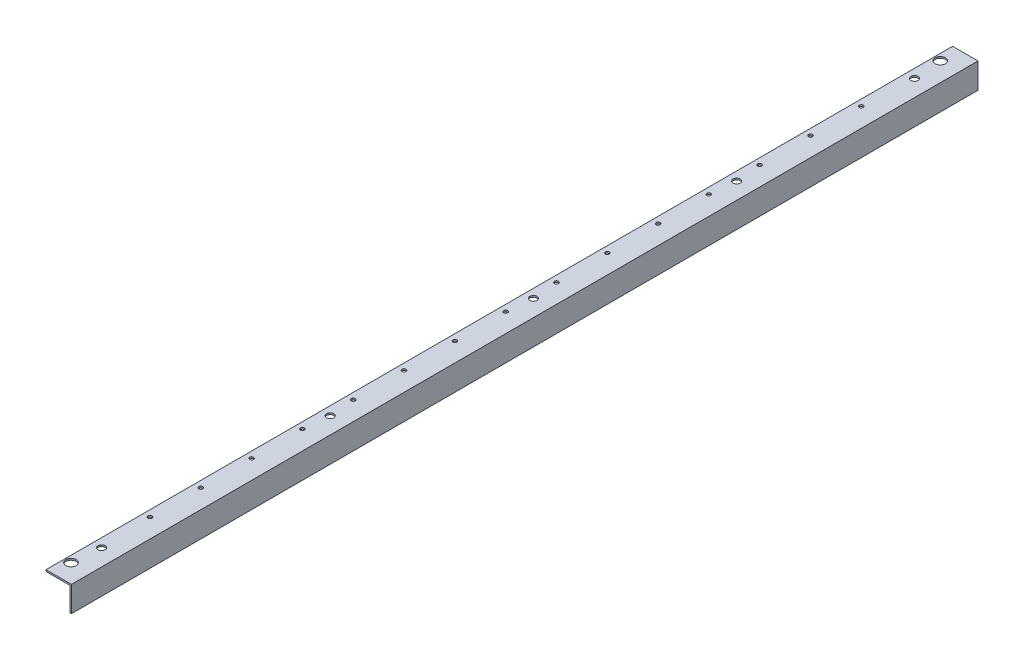
from build123d import *

# Parameters (mm, degrees)
BOSS_EXTRUDE1_DEPTH = 1812.925
SKETCH2_R           = 10.31875
SKETCH2_R_2         = 7.14375
CUT_EXTRUDE1_DEPTH  = 51.8
SKETCH4_R           = 3.96875
CUT_EXTRUDE3_DEPTH  = 44.45
LPATTERN1_COUNT     = 15
LPATTERN1_PITCH     = 101.6


with BuildPart() as part:
    # Sketch1 → Boss-Extrude1 (new body)
    with BuildSketch(Plane.XY):
        Polygon((0, 0), (-50.8, 0), (-50.8, -3.175), (-3.175, -3.175), (-3.175, -50.8), (0, -50.8), align=None)
    extrude(amount=BOSS_EXTRUDE1_DEPTH)

    # Sketch2 → Cut-Extrude1 (cut, through all)
    with BuildSketch(Plane(origin=(0, 0, 0), x_dir=(1, 0, 0), z_dir=(0, 1, 0))):
        with Locations((-38.1, -37.30625)):
            Circle(SKETCH2_R)
        with Locations((-38.1, -1775.61875)):
            Circle(SKETCH2_R)
        with Locations((-33.3375, -93.6625)):
            Circle(SKETCH2_R_2)
        with Locations((-33.3375, -449.2625)):
            Circle(SKETCH2_R_2)
        with Locations((-33.3375, -855.6625)):
            Circle(SKETCH2_R_2)
        with Locations((-33.3375, -1262.0625)):
            Circle(SKETCH2_R_2)
        with Locations((-33.3375, -1719.2625)):
            Circle(SKETCH2_R_2)
    extrude(amount=-CUT_EXTRUDE1_DEPTH, mode=Mode.SUBTRACT)

    # Sketch4 → Cut-Extrude3 (cut)
    with BuildSketch(Plane(origin=(-2.029899632, 0, 893.163272881), x_dir=(1, 0, 0), z_dir=(0, 1, 0))):
        with Locations((-36.070100368, 697.900772881)):
            Circle(SKETCH4_R)
    cut_extrude3 = extrude(amount=-CUT_EXTRUDE3_DEPTH, mode=Mode.SUBTRACT)

    # LPattern1: Cut-Extrude3 ×15
    with Locations(*[(0, 0, i * LPATTERN1_PITCH) for i in range(1, LPATTERN1_COUNT)]):
        add(cut_extrude3, mode=Mode.SUBTRACT)


solid = part.part
